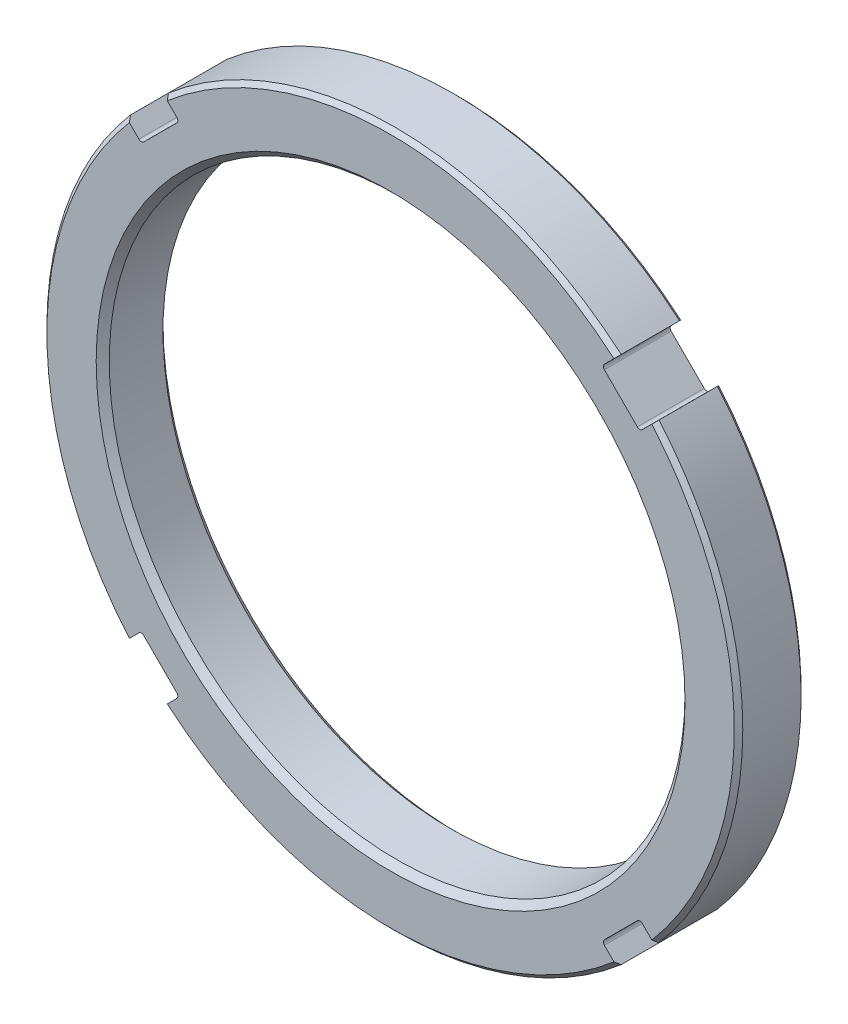
from build123d import *

# Parameters (mm, degrees)
SKETCH1_R                = 41.275
SKETCH1_R_2              = 34.1503
EXTRUDE1_DEPTH           = 7.9248
CHAMFER1_SIZE            = 0.503174
CHAMFER2_SIZE            = 0.7747
CUT_EXTRUDE1_DEPTH       = 8.9248
FILLET1_R                = 0.4064
CIRPATTERN1_COUNT        = 4
FILLET1_OF_CIRPATTERN1_R = 0.4064


with BuildPart() as part:
    # Sketch1 → Extrude1 (new body)
    with BuildSketch(Plane.XY):
        Circle(SKETCH1_R)
        Circle(SKETCH1_R_2, mode=Mode.SUBTRACT)
    extrude(amount=EXTRUDE1_DEPTH)

    # Chamfer1
    chamfer1_edges = [part.edges().sort_by_distance(p)[0] for p in [
        (-41.275, 0, 0),
        (-41.275, 0, 7.9248),
    ]]
    chamfer(chamfer1_edges, length=CHAMFER1_SIZE)

    # Chamfer2
    chamfer2_edges = [part.edges().sort_by_distance(p)[0] for p in [
        (-34.1503, 0, 0),
        (-34.1503, 0, 7.9248),
    ]]
    chamfer(chamfer2_edges, length=CHAMFER2_SIZE)

    # Sketch2 → Cut-Extrude1 (cut, through all)
    with BuildSketch(Plane.XY.offset(7.9248)):
        with BuildLine():
            Line((26.854291633, 31.344419693), (25.07287509, 29.563003151))
            Line((25.07287509, 29.563003151), (29.563003151, 25.07287509))
            Line((29.563003151, 25.07287509), (31.344419693, 26.854291633))
            ThreePointArc((31.344419693, 26.854291633), (29.185832393, 29.185832393), (26.854291633, 31.344419693))
        make_face()
    cut_extrude1 = extrude(amount=-CUT_EXTRUDE1_DEPTH, mode=Mode.SUBTRACT)

    # Fillet1
    fillet1_edges = [part.edges().sort_by_distance(p)[0] for p in [
        (29.563003151, 25.07287509, 3.9624),
        (25.07287509, 29.563003151, 3.9624),
    ]]
    fillet(fillet1_edges, radius=FILLET1_R)

    # CirPattern1: Cut-Extrude1 ×4 about axis
    cirpattern1_axis = Axis((0, 0, 0), (0, 0, 1))
    for i in range(1, CIRPATTERN1_COUNT):
        add(cut_extrude1.rotate(cirpattern1_axis, i * 360 / CIRPATTERN1_COUNT), mode=Mode.SUBTRACT)

    # Fillet1 of CirPattern1
    fillet1_of_cirpattern1_edges = [part.edges().sort_by_distance(p)[0] for p in [
        (-25.07287509, 29.563003151, 3.9624),
        (-29.563003151, 25.07287509, 3.9624),
        (-29.563003151, -25.07287509, 3.9624),
        (-25.07287509, -29.563003151, 3.9624),
        (25.07287509, -29.563003151, 3.9624),
        (29.563003151, -25.07287509, 3.9624),
    ]]
    fillet(fillet1_of_cirpattern1_edges, radius=FILLET1_OF_CIRPATTERN1_R)


solid = part.part
